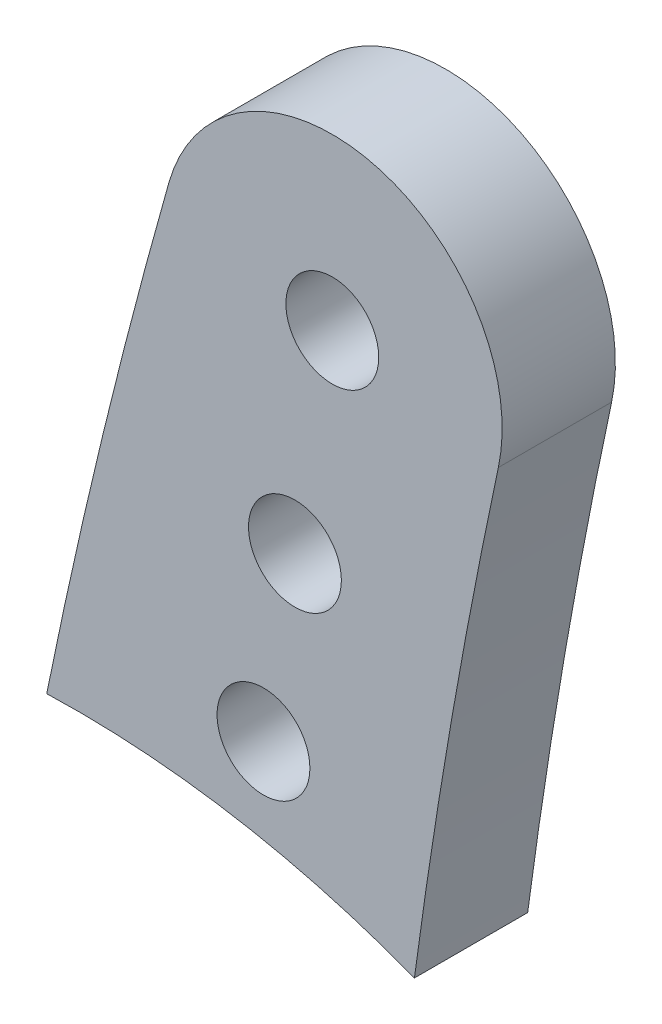
from build123d import *

# Parameters (mm, degrees)
SCHIZZO1_R                   = 2.05
ESTRUSIONE_ESTRUSIONE1_DEPTH = 5


with BuildPart() as part:
    # Schizzo1 → Estrusione-Estrusione1 (new body)
    with BuildSketch(Plane.XY):
        with BuildLine():
            ThreePointArc((7.023974797, 138.427683332), (1.499753731, 147.278176914), (-7.525391936, 142.044153534))
            ThreePointArc((-7.525391936, 142.044153534), (-10.43439027, 130.976285076), (-12.919154962, 119.805522885))
            ThreePointArc((-12.919154962, 119.805522885), (-4.662795864, 119.243774443), (3.317101425, 117.051910825))
            ThreePointArc((3.317101425, 117.051910825), (4.959663683, 127.776365806), (7.023974797, 138.427683332))
        make_face()
        with Locations((-0.309434746, 139.999658036)):
            Circle(SCHIZZO1_R, mode=Mode.SUBTRACT)
        with Locations((-1.959092434, 130.643984382)):
            Circle(SCHIZZO1_R, mode=Mode.SUBTRACT)
        with Locations((-3.348277855, 122.765522358)):
            Circle(SCHIZZO1_R, mode=Mode.SUBTRACT)
    extrude(amount=ESTRUSIONE_ESTRUSIONE1_DEPTH)


solid = part.part
